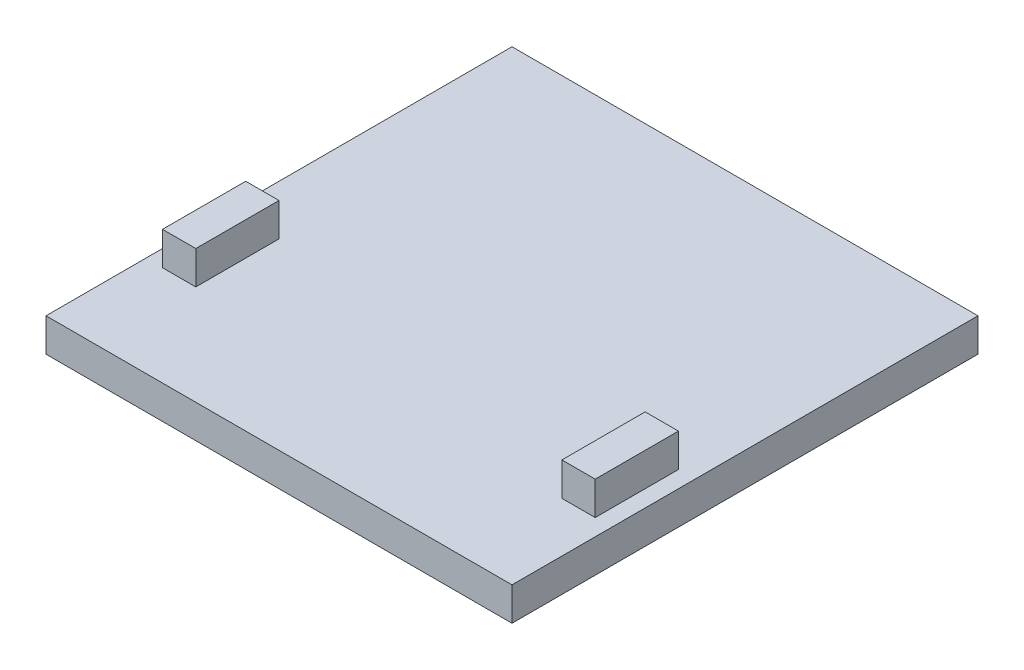
from build123d import *

# Parameters (mm, degrees)
SKETCH1_W           = 711.2
SKETCH1_H           = 711.2
BOSS_EXTRUDE1_DEPTH = 50.8
SKETCH2_W           = 50.8
SKETCH2_H           = 127
BOSS_EXTRUDE2_DEPTH = 50.8


with BuildPart() as part:
    # Sketch1 → Boss-Extrude1 (new body)
    with BuildSketch(Plane(origin=(0, 0, 0), x_dir=(1, 0, 0), z_dir=(0, 1, 0))):
        Rectangle(SKETCH1_W, SKETCH1_H)
    extrude(amount=BOSS_EXTRUDE1_DEPTH)

    # Sketch2 → Boss-Extrude2 (add)
    with BuildSketch(Plane(origin=(0, 50.8, 0), x_dir=(1, 0, 0), z_dir=(0, 1, 0))):
        with Locations((304.8, -139.7)):
            Rectangle(SKETCH2_W, SKETCH2_H)
        with Locations((-304.8, -139.7)):
            Rectangle(SKETCH2_W, SKETCH2_H)
    extrude(amount=BOSS_EXTRUDE2_DEPTH)


solid = part.part
